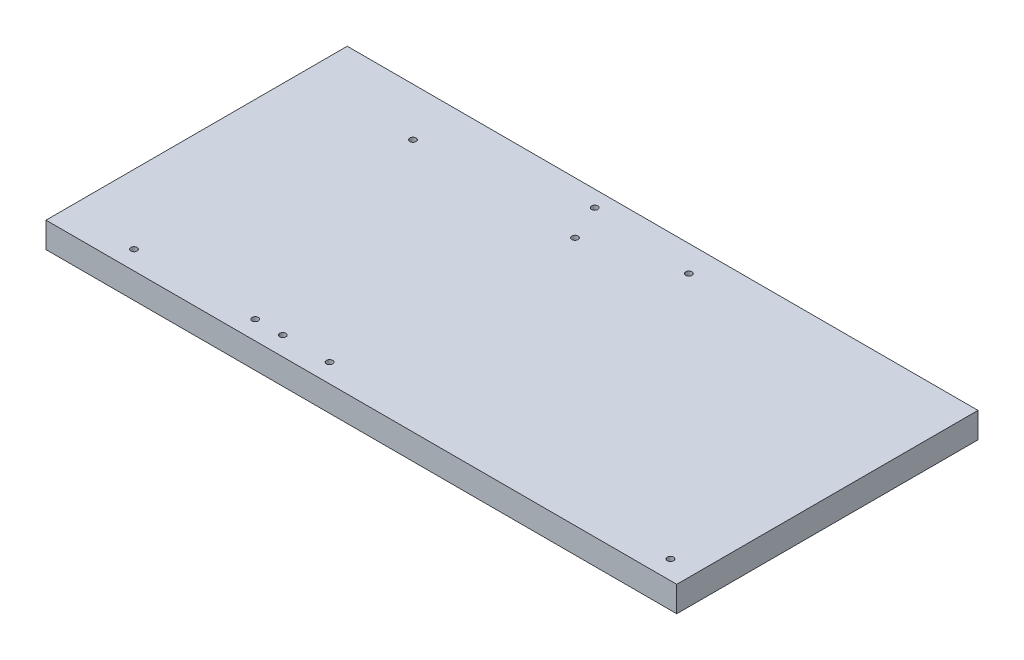
from build123d import *

# Parameters (mm, degrees)
SKETCH1_W                   = 638.175
SKETCH1_H                   = 304.8
JIG_STOCK_DEPTH             = 25.8318
SKETCH3_R                   = 3.175
FRONT_BOTTOM_WISHBONE_DEPTH = 26.8318
SKETCH5_R                   = 3.175
FRONT_TOP_WISHBONE_DEPTH    = 26.8318
SKETCH6_R                   = 3.175
REAR_TOP_WISHBONE_DEPTH     = 26.8318
SKETCH7_R                   = 3.175
REAR_BOTTOM_WISHBONE_DEPTH  = 26.8318


with BuildPart() as part:
    # Sketch1 → Jig stock (new body)
    with BuildSketch(Plane(origin=(0, 0, 0), x_dir=(1, 0, 0), z_dir=(0, 1, 0))):
        with Locations((64.305961538, -3.907692308)):
            Rectangle(SKETCH1_W, SKETCH1_H)
    extrude(amount=JIG_STOCK_DEPTH)

    # Sketch3 → Front bottom wishbone (cut, through all)
    with BuildSketch(Plane(origin=(0, 25.8318, 0), x_dir=(1, 0, 0), z_dir=(0, 1, 0))):
        with Locations((357.993461538, -137.257692308)):
            Circle(SKETCH3_R)
        with Locations((-62.173338462, -137.257692308)):
            Circle(SKETCH3_R)
        with Locations((11.899509072, 132.16909874)):
            Circle(SKETCH3_R)
    extrude(amount=-FRONT_BOTTOM_WISHBONE_DEPTH, mode=Mode.SUBTRACT)

    # Sketch5 → Front top wishbone (cut, through all)
    with BuildSketch(Plane(origin=(0, 25.8318, 0), x_dir=(1, 0, 0), z_dir=(0, 1, 0))):
        with Locations((13.127501538, -137.257692308)):
            Circle(SKETCH5_R)
        with Locations((117.27518671, 122.058176562)):
            Circle(SKETCH5_R)
    extrude(amount=-FRONT_TOP_WISHBONE_DEPTH, mode=Mode.SUBTRACT)

    # Sketch6 → Rear top wishbone (cut, through all)
    with BuildSketch(Plane(origin=(0, 25.8318, 0), x_dir=(1, 0, 0), z_dir=(0, 1, 0))):
        with Locations((-34.253658462, -137.257692308)):
            Circle(SKETCH6_R)
        with Locations((28.279213606, 95.847599015)):
            Circle(SKETCH6_R)
    extrude(amount=-REAR_TOP_WISHBONE_DEPTH, mode=Mode.SUBTRACT)

    # Sketch7 → Rear bottom wishbone (cut, through all)
    with BuildSketch(Plane(origin=(0, 25.8318, 0), x_dir=(1, 0, 0), z_dir=(0, 1, 0))):
        with Locations((-184.761358462, -137.257692308)):
            Circle(SKETCH7_R)
        with Locations((-139.599326464, 99.762159573)):
            Circle(SKETCH7_R)
    extrude(amount=-REAR_BOTTOM_WISHBONE_DEPTH, mode=Mode.SUBTRACT)


solid = part.part
